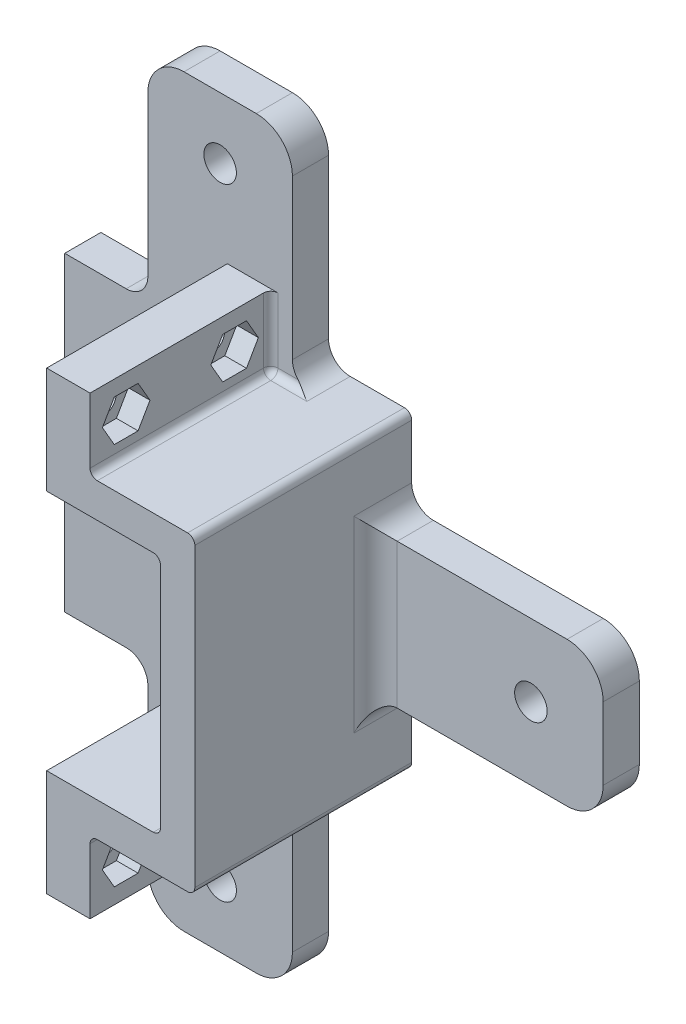
from build123d import *

# Parameters (mm, degrees)
SKETCH1_W           = 43
SKETCH1_H           = 43
SKETCH1_W_2         = 33
SKETCH1_H_2         = 33
BOSS_EXTRUDE1_DEPTH = 25
SKETCH3_W           = 43
SKETCH3_H           = 43
BOSS_EXTRUDE2_DEPTH = 5
SKETCH4_W           = 20
SKETCH4_H           = 5
BOSS_EXTRUDE3_DEPTH = 30
SKETCH5_R           = 2.25
CUT_EXTRUDE1_DEPTH  = 6
SKETCH_1_W          = 21.5
SKETCH_1_H          = 43
CUT_EXTRUDE_1_DEPTH = 25
SKETCH_3_W          = 25
SKETCH_3_H          = 10
EXTRUDE_1_DEPTH     = 7
FILLET_1_R          = 1
SKETCH_4_R          = 1.6
CUT_EXTRUDE_2_DEPTH = 22.5
CUT_EXTRUDE_3_DEPTH = 3
SKETCH_6_W          = 16.75
SKETCH_6_H          = 33.5
CUT_EXTRUDE_4_DEPTH = 25
FILLET_2_R          = 1
FILLET_3_R          = 1
FILLET_4_R          = 5
FILLET_6_R          = 1
CUT_EXTRUDE_5_DEPTH = 1
SKETCH_9_W          = 5
SKETCH_9_H          = 20
EXTRUDE_2_DEPTH     = 31.5
SKETCH_10_R         = 2.25
CUT_EXTRUDE_6_DEPTH = 6
FILLET_7_R          = 5
FILLET_8_R          = 3
FILLET_9_R          = 1


with BuildPart() as part:
    # Sketch1 → Boss-Extrude1 (new body)
    with BuildSketch(Plane.XY):
        with Locations((16.5, 16.5)):
            Rectangle(SKETCH1_W, SKETCH1_H)
        with Locations((16.5, 16.5)):
            Rectangle(SKETCH1_W_2, SKETCH1_H_2, mode=Mode.SUBTRACT)
    extrude(amount=BOSS_EXTRUDE1_DEPTH)

    # Sketch3 → Boss-Extrude2 (add)
    with BuildSketch(Plane(origin=(0, 0, 0), x_dir=(-1, 0, 0), z_dir=(0, 0, -1))):
        with Locations((-16.5, 16.5)):
            Rectangle(SKETCH3_W, SKETCH3_H)
    extrude(amount=BOSS_EXTRUDE2_DEPTH)

    # Sketch4 → Boss-Extrude3 (add)
    with BuildSketch(Plane(origin=(0, 38, 0), x_dir=(1, 0, 0), z_dir=(0, 1, 0))):
        with Locations((16.5, 2.5)):
            Rectangle(SKETCH4_W, SKETCH4_H)
    boss_extrude3 = extrude(amount=BOSS_EXTRUDE3_DEPTH)

    # Sketch5 → Cut-Extrude1 (cut, through all)
    with BuildSketch(Plane.XY):
        with Locations((16.5, 59.5)):
            Circle(SKETCH5_R)
    cut_extrude1 = extrude(amount=-CUT_EXTRUDE1_DEPTH, mode=Mode.SUBTRACT)

    # Mirror1: Boss-Extrude3, Cut-Extrude1 across plane
    add(boss_extrude3.mirror(Plane(origin=(0, 16.5, 0), x_dir=(0, 0, 1), z_dir=(0, -1, 0))))
    add(cut_extrude1.mirror(Plane(origin=(0, 16.5, 0), x_dir=(0, 0, 1), z_dir=(0, -1, 0))), mode=Mode.SUBTRACT)

    # Эскиз1 → Вырез-Вытянуть1 (cut)
    with BuildSketch(Plane.XY.offset(25)):
        with Locations((5.75, 16.5)):
            Rectangle(SKETCH_1_W, SKETCH_1_H)
    extrude(amount=-CUT_EXTRUDE_1_DEPTH, mode=Mode.SUBTRACT)

    # Эскиз3 → Бобышка-Вытянуть1 (add)
    with BuildSketch(Plane.ZY.offset(-16.5)):
        with Locations((12.5, -10)):
            Rectangle(SKETCH_3_W, SKETCH_3_H)
    extrude_1 = extrude(amount=-EXTRUDE_1_DEPTH)

    # Скругление1
    fillet_1_edges = [part.edges().sort_by_distance(p)[0] for p in [
        (23.5, -5, 12.5),
    ]]
    fillet(fillet_1_edges, radius=FILLET_1_R)

    # Эскиз4 → Вырез-Вытянуть2 (cut, through all)
    with BuildSketch(Plane.ZY.offset(-16.5)):
        with Locations((20, -10)):
            Circle(SKETCH_4_R)
        with Locations((5, -10)):
            Circle(SKETCH_4_R)
    cut_extrude_2 = extrude(amount=-CUT_EXTRUDE_2_DEPTH, mode=Mode.SUBTRACT)

    # Эскиз5 → Вырез-Вытянуть3 (cut)
    with BuildSketch(Plane(origin=(23.5, 0, 0), x_dir=(0, 0, -1), z_dir=(1, 0, 0))):
        Polygon((-18.354551733, -12.85), (-16.709103466, -10), (-18.354551733, -7.15), (-21.645448267, -7.15), (-23.290896534, -10), (-21.645448267, -12.85), align=None)
        Polygon((-6.645448267, -12.85), (-3.354551733, -12.85), (-1.709103466, -10), (-3.354551733, -7.15), (-6.645448267, -7.15), (-8.290896534, -10), align=None)
    cut_extrude_3 = extrude(amount=-CUT_EXTRUDE_3_DEPTH, mode=Mode.SUBTRACT)

    # Зеркальное отражение2: Бобышка-Вытянуть1 across plane
    add(extrude_1.mirror(Plane(origin=(0, 16.5, 0), x_dir=(0, 0, 1), z_dir=(0, -1, 0))))

    # Зеркальное отражение3: Вырез-Вытянуть2 across plane
    add(cut_extrude_2.mirror(Plane(origin=(0, 16.5, 0), x_dir=(0, 0, 1), z_dir=(0, -1, 0))), mode=Mode.SUBTRACT)

    # Зеркальное отражение4: Вырез-Вытянуть3 across plane
    add(cut_extrude_3.mirror(Plane(origin=(0, 16.5, 0), x_dir=(0, 0, 1), z_dir=(0, -1, 0))), mode=Mode.SUBTRACT)

    # Эскиз6 → Вырез-Вытянуть4 (cut)
    with BuildSketch(Plane.XY.offset(25)):
        with Locations((24.875, 16.5)):
            Rectangle(SKETCH_6_W, SKETCH_6_H)
    extrude(amount=-CUT_EXTRUDE_4_DEPTH, mode=Mode.SUBTRACT)

    # Скругление2
    fillet_2_edges = [part.edges().sort_by_distance(p)[0] for p in [
        (23.5, 38, 12.5),
    ]]
    fillet(fillet_2_edges, radius=FILLET_2_R)

    # Скругление3
    fillet_3_edges = [part.edges().sort_by_distance(p)[0] for p in [
        (25.5, -5, 0),
        (23.5, -10.5, 0),
        (23.792893219, -5.292893219, 0),
        (23.5, 43.5, 0),
        (25.5, 38, 0),
        (23.792893219, 38.292893219, 0),
    ]]
    fillet(fillet_3_edges, radius=FILLET_3_R)

    # Скругление4
    fillet_4_edges = [part.edges().sort_by_distance(p)[0] for p in [
        (6.5, -35, -2.5),
        (26.5, -35, -2.5),
        (6.5, 68, -2.5),
        (26.5, 68, -2.5),
    ]]
    fillet(fillet_4_edges, radius=FILLET_4_R)

    # Скругление6
    fillet_6_edges = [part.edges().sort_by_distance(p)[0] for p in [
        (33.25, 33.25, 12.5),
        (33.25, -0.25, 12.5),
        (24.875, 33.25, 0),
        (33.25, 16.5, 0),
        (24.875, -0.25, 0),
    ]]
    fillet(fillet_6_edges, radius=FILLET_6_R)

    # Эскиз7 → Вырез-Вытянуть5 (cut)
    with BuildSketch(Plane.ZY.offset(-16.5)):
        with BuildLine():
            Line((0, 48), (0, 32.25))
            ThreePointArc((0, 32.25), (0.292893219, 32.957106781), (1, 33.25))
            Line((1, 33.25), (25, 33.25))
            Line((25, 33.25), (25, 48))
            Line((25, 48), (0, 48))
        make_face()
        with BuildLine():
            Line((25, -15), (25, -0.25))
            Line((25, -0.25), (1, -0.25))
            ThreePointArc((1, -0.25), (0.292893219, 0.042893219), (0, 0.75))
            Line((0, 0.75), (0, -15))
            Line((0, -15), (25, -15))
        make_face()
    extrude(amount=-CUT_EXTRUDE_5_DEPTH, mode=Mode.SUBTRACT)

    # Эскиз9 → Бобышка-Вытянуть2 (add)
    with BuildSketch(Plane(origin=(38, 0, 0), x_dir=(0, 0, -1), z_dir=(1, 0, 0))):
        with Locations((2.5, 16.5)):
            Rectangle(SKETCH_9_W, SKETCH_9_H)
    extrude(amount=EXTRUDE_2_DEPTH)

    # Эскиз10 → Вырез-Вытянуть6 (cut, through all)
    with BuildSketch(Plane.XY):
        with Locations((59.5, 16.5)):
            Circle(SKETCH_10_R)
    extrude(amount=-CUT_EXTRUDE_6_DEPTH, mode=Mode.SUBTRACT)

    # Скругление7
    fillet_7_edges = [part.edges().sort_by_distance(p)[0] for p in [
        (69.5, 6.5, -2.5),
        (69.5, 26.5, -2.5),
    ]]
    fillet(fillet_7_edges, radius=FILLET_7_R)

    # Скругление8
    fillet_8_edges = [part.edges().sort_by_distance(p)[0] for p in [
        (6.5, -5, -2.5),
        (6.5, 38, -2.5),
        (26.5, 38, -2),
        (26.5, -5, -2),
        (38, 6.5, -2.5),
        (38, 26.5, -2.5),
        (38, 16.5, 0),
    ]]
    fillet(fillet_8_edges, radius=FILLET_8_R)

    # Скругление9
    fillet_9_edges = [part.edges().sort_by_distance(p)[0] for p in [
        (38, -5, 10),
        (38, 38, 10),
    ]]
    fillet(fillet_9_edges, radius=FILLET_9_R)


solid = part.part
